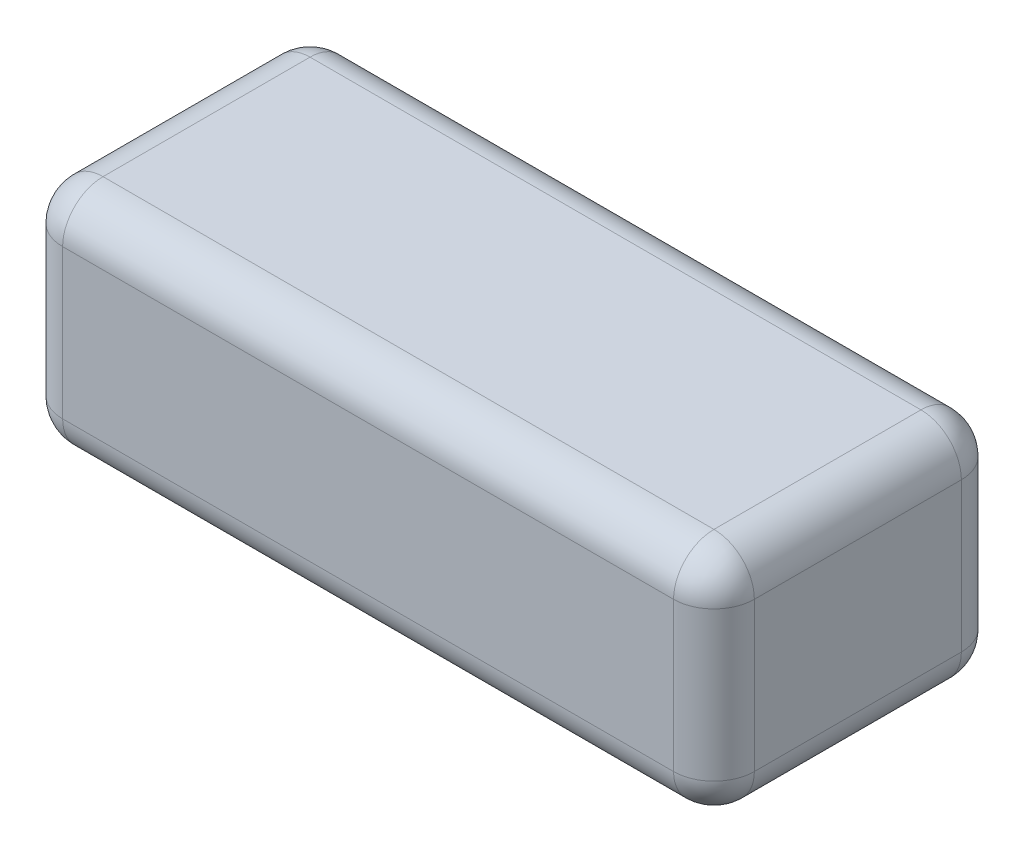
from build123d import *

# Parameters (mm, degrees)
SKETCH1_W           = 137
SKETCH1_H           = 57
BOSS_EXTRUDE1_DEPTH = 45.54
FILLET1_R           = 8


with BuildPart() as part:
    # Sketch1 → Boss-Extrude1 (new body)
    with BuildSketch(Plane(origin=(0, 0, 0), x_dir=(1, 0, 0), z_dir=(0, 1, 0))):
        Rectangle(SKETCH1_W, SKETCH1_H)
    extrude(amount=BOSS_EXTRUDE1_DEPTH)

    # Fillet1
    fillet1_edges = [part.edges().sort_by_distance(p)[0] for p in [
        (68.5, 45.54, 0),
        (0, 45.54, -28.5),
        (-68.5, 45.54, 0),
        (0, 0, -28.5),
        (68.5, 0, 0),
        (0, 0, 28.5),
        (-68.5, 0, 0),
        (-68.5, 22.77, -28.5),
        (68.5, 22.77, -28.5),
        (68.5, 22.77, 28.5),
        (-68.5, 22.77, 28.5),
        (0, 45.54, 28.5),
    ]]
    fillet(fillet1_edges, radius=FILLET1_R)


solid = part.part
